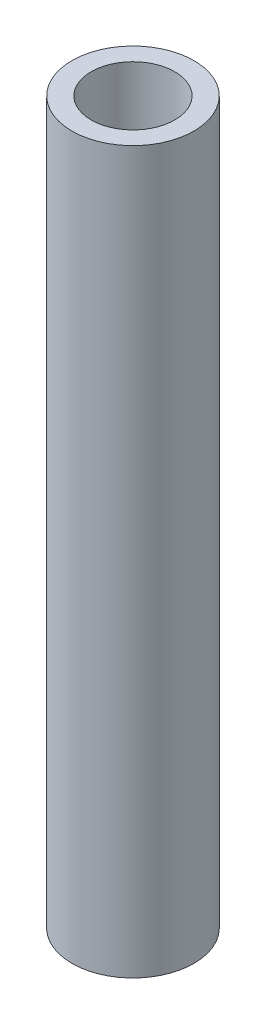
from build123d import *

# Parameters (mm, degrees)
SKETCH1_R           = 12.7
SKETCH1_R_2         = 8.7
BOSS_EXTRUDE1_DEPTH = 150


with BuildPart() as part:
    # Sketch1 → Boss-Extrude1 (new body)
    with BuildSketch(Plane(origin=(0, 0, 0), x_dir=(1, 0, 0), z_dir=(0, 1, 0))):
        Circle(SKETCH1_R)
        Circle(SKETCH1_R_2, mode=Mode.SUBTRACT)
    extrude(amount=BOSS_EXTRUDE1_DEPTH)


solid = part.part
